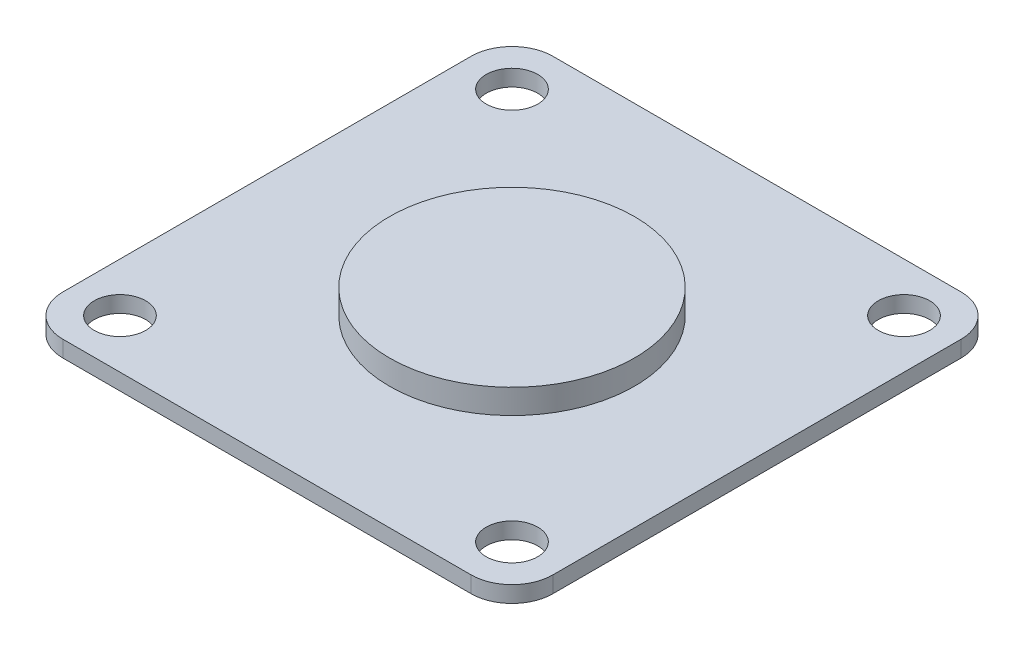
from build123d import *

# Parameters (mm, degrees)
ESQUISSE1_R        = 3.15
BOSS_EXTRU_1_DEPTH = 2
ESQUISSE2_R        = 15
BOSS_EXTRU_2_DEPTH = 3


with BuildPart() as part:
    # Esquisse1 → Boss.-Extru.1 (new body)
    with BuildSketch(Plane(origin=(0, 0, 0), x_dir=(1, 0, 0), z_dir=(0, 1, 0))):
        with BuildLine():
            Line((-25, -30), (25, -30))
            ThreePointArc((25, -30), (28.535533906, -28.535533906), (30, -25))
            Line((30, -25), (30, 25))
            ThreePointArc((30, 25), (28.535533906, 28.535533906), (25, 30))
            Line((25, 30), (-25, 30))
            ThreePointArc((-25, 30), (-28.535533906, 28.535533906), (-30, 25))
            Line((-30, 25), (-30, -25))
            ThreePointArc((-30, -25), (-28.535533906, -28.535533906), (-25, -30))
        make_face()
        with Locations((-24, 24)):
            Circle(ESQUISSE1_R, mode=Mode.SUBTRACT)
        with Locations((24, 24)):
            Circle(ESQUISSE1_R, mode=Mode.SUBTRACT)
        with Locations((24, -24)):
            Circle(ESQUISSE1_R, mode=Mode.SUBTRACT)
        with Locations((-24, -24)):
            Circle(ESQUISSE1_R, mode=Mode.SUBTRACT)
    extrude(amount=BOSS_EXTRU_1_DEPTH)

    # Esquisse2 → Boss.-Extru.2 (add)
    with BuildSketch(Plane(origin=(0, 2, 0), x_dir=(1, 0, 0), z_dir=(0, 1, 0))):
        Circle(ESQUISSE2_R)
    extrude(amount=BOSS_EXTRU_2_DEPTH)


solid = part.part
